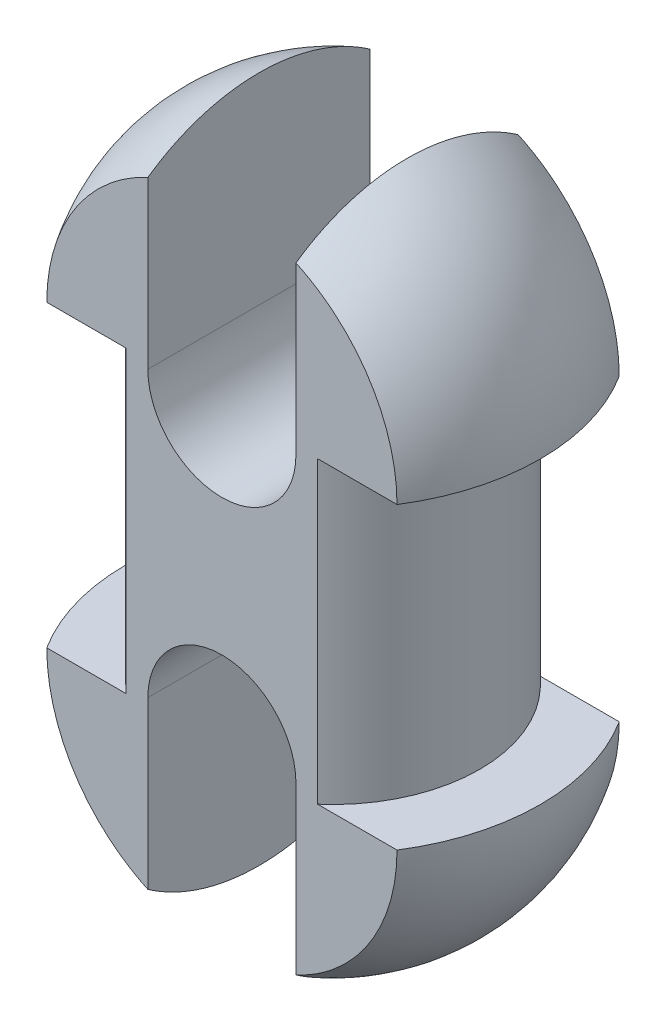
from build123d import *

# Parameters (mm, degrees)
ESBO_O2_OUTSIDE_W          = 42.476
ESBO_O2_OUTSIDE_H          = 42.476
ESBO_O2_OUTSIDE_W_2        = 28
ESBO_O2_OUTSIDE_H_2        = 15
CORTE_EXTRUS_O1_DEPTH      = 25.1
CORTE_EXTRUS_O1_DEPTH_BACK = 25.1
CORTE_EXTRUS_O2_DEPTH      = 16


with BuildPart() as part:
    # Esboço1 → Revolução1 (revolve)
    with BuildSketch(Plane.XY):
        with BuildLine():
            Line((0, 24.1), (0, -24.1))
            ThreePointArc((0, -24.1), (9.899494937, -19.999494937), (14, -10.1))
            Line((14, -10.1), (9.9, -10.1))
            Line((9.9, -10.1), (9.9, 10.1))
            Line((9.9, 10.1), (14, 10.1))
            ThreePointArc((14, 10.1), (9.899494937, 19.999494937), (0, 24.1))
        make_face()
    revolve(axis=Axis((0, -24.1, 0), (0, 1, 0)))

    # Esboço2 outside → Corte-extrusão1 (cut, two sides)
    with BuildSketch(Plane(origin=(0, 0, 0), x_dir=(1, 0, 0), z_dir=(0, 1, 0))) as corte_extrus_o1_sk:
        Rectangle(ESBO_O2_OUTSIDE_W, ESBO_O2_OUTSIDE_H)
        Rectangle(ESBO_O2_OUTSIDE_W_2, ESBO_O2_OUTSIDE_H_2, mode=Mode.SUBTRACT)
    extrude(amount=CORTE_EXTRUS_O1_DEPTH, mode=Mode.SUBTRACT)
    extrude(corte_extrus_o1_sk.sketch, amount=-CORTE_EXTRUS_O1_DEPTH_BACK, mode=Mode.SUBTRACT)

    # Esboço3 → Corte-extrusão2 (cut, through all)
    with BuildSketch(Plane(origin=(0, 0, -7.5), x_dir=(-1, 0, 0), z_dir=(0, 0, -1))):
        with BuildLine():
            Line((5, 24.1), (5, 9.6))
            ThreePointArc((5, 9.6), (0, 4.6), (-5, 9.6))
            Line((-5, 9.6), (-5, 24.1))
            ThreePointArc((-5, 24.1), (0, 29.1), (5, 24.1))
        make_face()
        with BuildLine():
            Line((-5, -24.1), (-5, -9.6))
            ThreePointArc((-5, -9.6), (0, -4.6), (5, -9.6))
            Line((5, -9.6), (5, -24.1))
            ThreePointArc((5, -24.1), (0, -29.1), (-5, -24.1))
        make_face()
    extrude(amount=-CORTE_EXTRUS_O2_DEPTH, mode=Mode.SUBTRACT)


solid = part.part
